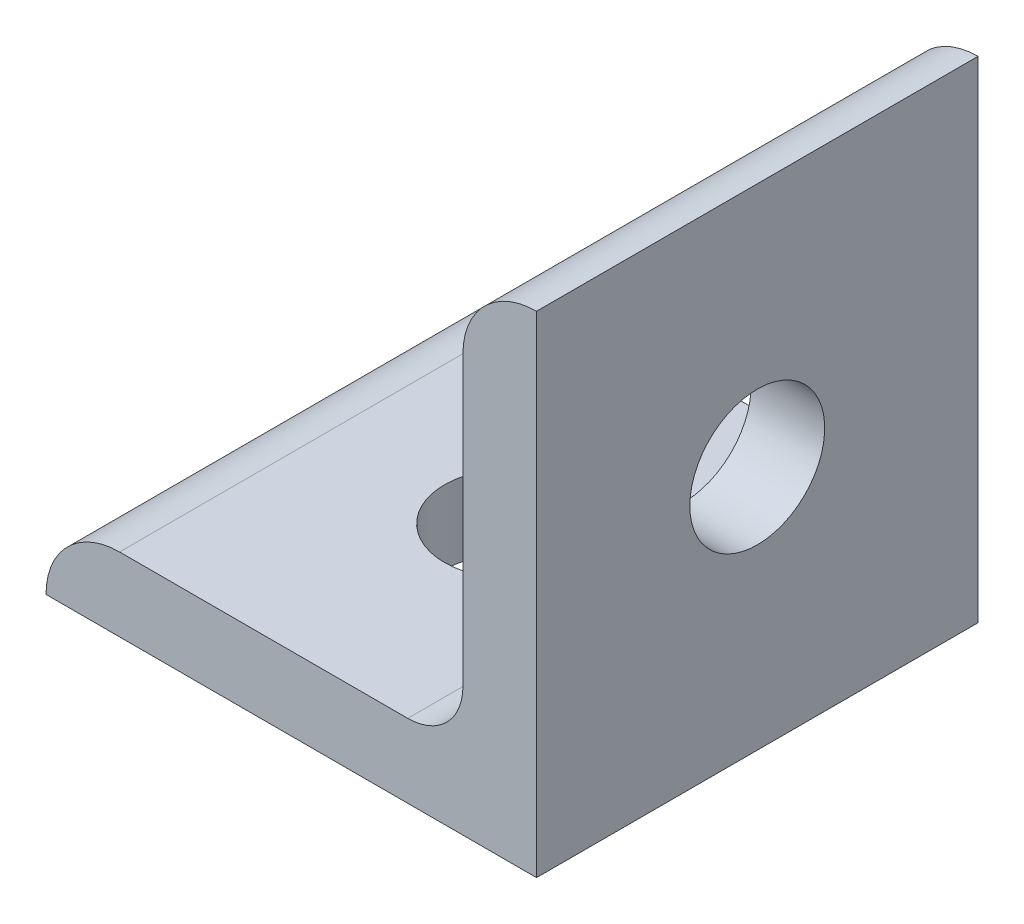
from build123d import *

# Parameters (mm, degrees)
EXTRUDE1_DEPTH     = 9
SKETCH2_R          = 2.75
CUT_EXTRUDE1_DEPTH = 4
SKETCH3_R          = 2.75
CUT_EXTRUDE2_DEPTH = 4


with BuildPart() as part:
    # Sketch1 → Extrude1 (new body, symmetric)
    with BuildSketch(Plane.XY):
        with BuildLine():
            Line((0, 0), (0, 20))
            ThreePointArc((0, 20), (-2.121320344, 19.121320344), (-3, 17))
            Line((-3, 17), (-3, 5.25))
            ThreePointArc((-3, 5.25), (-3.659009742, 3.659009742), (-5.25, 3))
            Line((-5.25, 3), (-17, 3))
            ThreePointArc((-17, 3), (-19.121320344, 2.121320344), (-20, 0))
            Line((-20, 0), (0, 0))
        make_face()
    extrude(amount=EXTRUDE1_DEPTH, both=True)

    # Sketch2 → Cut-Extrude1 (cut, through all)
    with BuildSketch(Plane(origin=(0, 3, 0), x_dir=(1, 0, 0), z_dir=(0, 1, 0))):
        with Locations((-10, 0)):
            Circle(SKETCH2_R)
    extrude(amount=-CUT_EXTRUDE1_DEPTH, mode=Mode.SUBTRACT)

    # Sketch3 → Cut-Extrude2 (cut, through all)
    with BuildSketch(Plane.ZY.offset(3)):
        with Locations((0, 10)):
            Circle(SKETCH3_R)
    extrude(amount=-CUT_EXTRUDE2_DEPTH, mode=Mode.SUBTRACT)


solid = part.part
